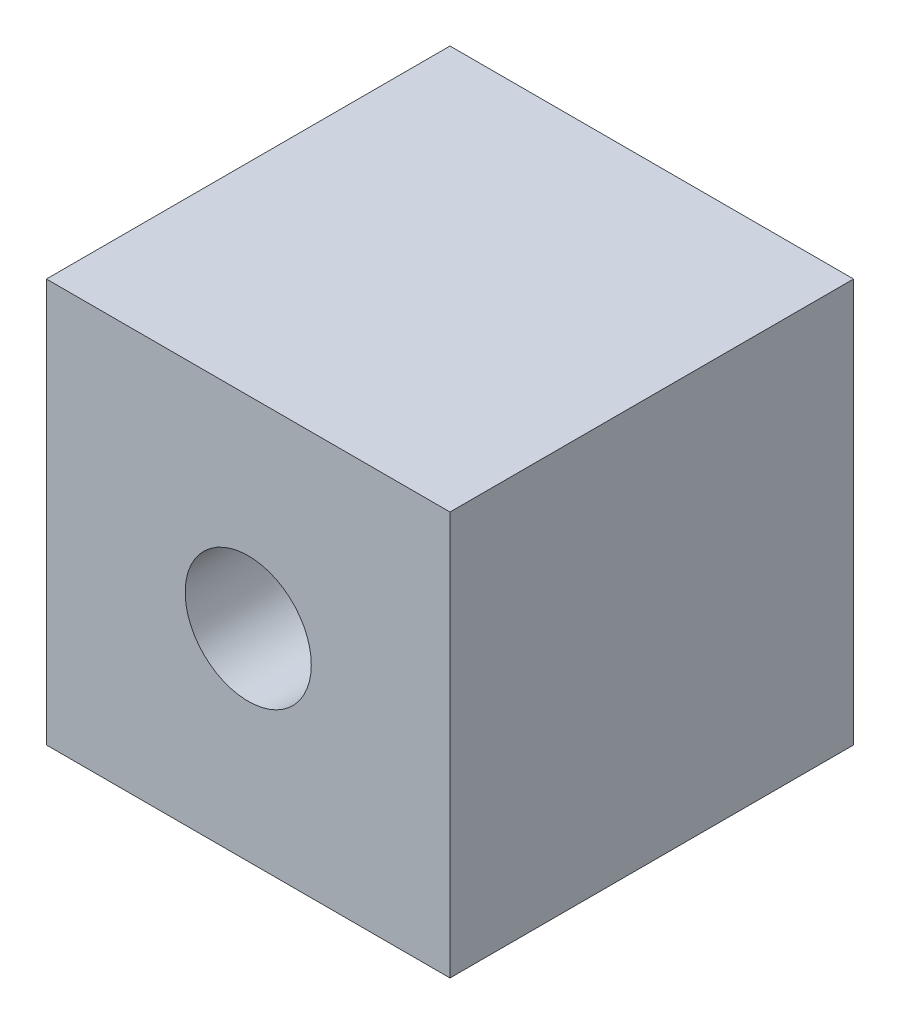
from build123d import *

# Parameters (mm, degrees)
SKETCH1_W           = 48
SKETCH1_H           = 48
BOSS_EXTRUDE1_DEPTH = 48
SKETCH2_R           = 7.5
CUT_EXTRUDE1_DEPTH  = 49


with BuildPart() as part:
    # Sketch1 → Boss-Extrude1 (new body)
    with BuildSketch(Plane(origin=(0, 0, 0), x_dir=(1, 0, 0), z_dir=(0, 1, 0))):
        Rectangle(SKETCH1_W, SKETCH1_H)
    extrude(amount=BOSS_EXTRUDE1_DEPTH)

    # Sketch2 → Cut-Extrude1 (cut, through all)
    with BuildSketch(Plane.XY.offset(24)):
        with Locations((0, 24)):
            Circle(SKETCH2_R)
    extrude(amount=-CUT_EXTRUDE1_DEPTH, mode=Mode.SUBTRACT)


solid = part.part
